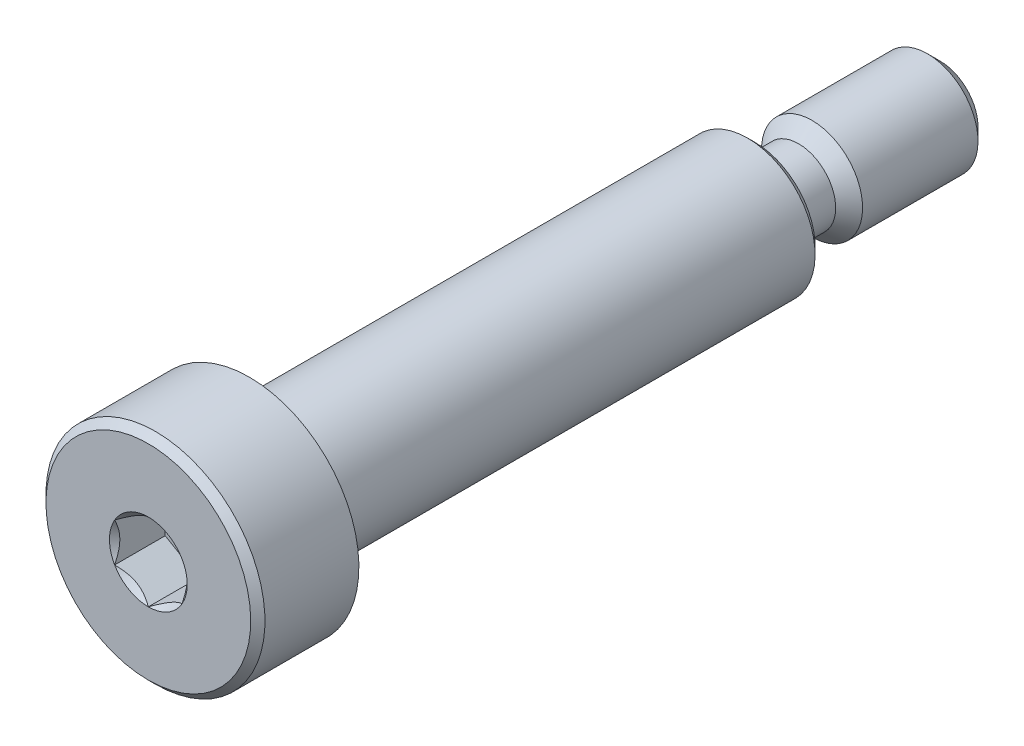
from build123d import *

# Parameters (mm, degrees)
SKETCH4_W          = 0.866666667
SKETCH4_H          = 0.866666667
CHAMFER1_SIZE      = 0.26
CHAMFER2_SIZE      = 0.75
CHAMFER3_SIZE      = 0.4225
CUT_EXTRUDE1_DEPTH = 3


with BuildPart() as part:
    # Sketch3 → Revolve1 (revolve)
    with BuildSketch(Plane(origin=(0, 0, 0), x_dir=(0, 0, -1), z_dir=(1, 0, 0))):
        Polygon((-23.5, 6.5), (-17.5, 6.5), (-17.5, 4), (12.5, 4), (12.5, 3), (23.5, 3), (23.5, 0), (-23.5, 0), align=None)
    revolve(axis=Axis((0, 0, -23.5), (0, 0, 1)))

    # Sketch4 → Cut-Revolve1 (revolve, cut)
    with BuildSketch(Plane(origin=(0, 0, 0), x_dir=(0, 0, -1), z_dir=(1, 0, 0))):
        with Locations((-17.066666666, 3.566666667)):
            Rectangle(SKETCH4_W, SKETCH4_H)
    revolve(axis=Axis((0, 0, -23.5), (0, 0, 1)), mode=Mode.SUBTRACT)

    # Chamfer1
    chamfer1_edges = [part.edges().sort_by_distance(p)[0] for p in [
        (0, -4, 16.633333333),
        (0, -3.133333333, 16.633333333),
    ]]
    chamfer(chamfer1_edges, length=CHAMFER1_SIZE)

    # Sketch6 → Cut-Revolve2 (revolve, cut)
    with BuildSketch(Plane(origin=(0, 0, 0), x_dir=(0, 0, -1), z_dir=(1, 0, 0))):
        with BuildLine():
            Line((12.5, 4), (16.9, 4))
            Line((16.9, 4), (15.1, 2.2))
            Line((15.1, 2.2), (13.3, 2.2))
            ThreePointArc((13.3, 2.2), (12.734314575, 2.434314575), (12.5, 3))
            Line((12.5, 3), (12.5, 4))
        make_face()
    revolve(axis=Axis((0, 0, -23.5), (0, 0, 1)), mode=Mode.SUBTRACT)

    # Chamfer2
    chamfer2_edges = [part.edges().sort_by_distance(p)[0] for p in [
        (0, -3, -23.5),
    ]]
    chamfer(chamfer2_edges, length=CHAMFER2_SIZE)

    # Chamfer3
    chamfer3_edges = [part.edges().sort_by_distance(p)[0] for p in [
        (0, -6.5, 23.5),
        (0, -4, -12.5),
    ]]
    chamfer(chamfer3_edges, length=CHAMFER3_SIZE)

    # Sketch8 → Cut-Extrude1 (cut)
    with BuildSketch(Plane.XY.offset(23.5)):
        Polygon((2, 1.154700538), (0, 2.309401077), (-2, 1.154700538), (-2, -1.154700538), (0, -2.309401077), (2, -1.154700538), align=None)
    extrude(amount=-CUT_EXTRUDE1_DEPTH, mode=Mode.SUBTRACT)

    # Cut-Extrude2 cone 1 section (through the dimple's axis) → Cut-Extrude2 (revolve, cut)
    with BuildSketch(Plane(origin=(0, 0, 23.5), x_dir=(0, -1, 0), z_dir=(1, 0, 0))):
        Polygon((0, 0), (2.309401077, 0), (0, 2.309401077), align=None)
    revolve(axis=Axis((0, 0, 23.5), (0, 0, -1)), mode=Mode.SUBTRACT)


solid = part.part
